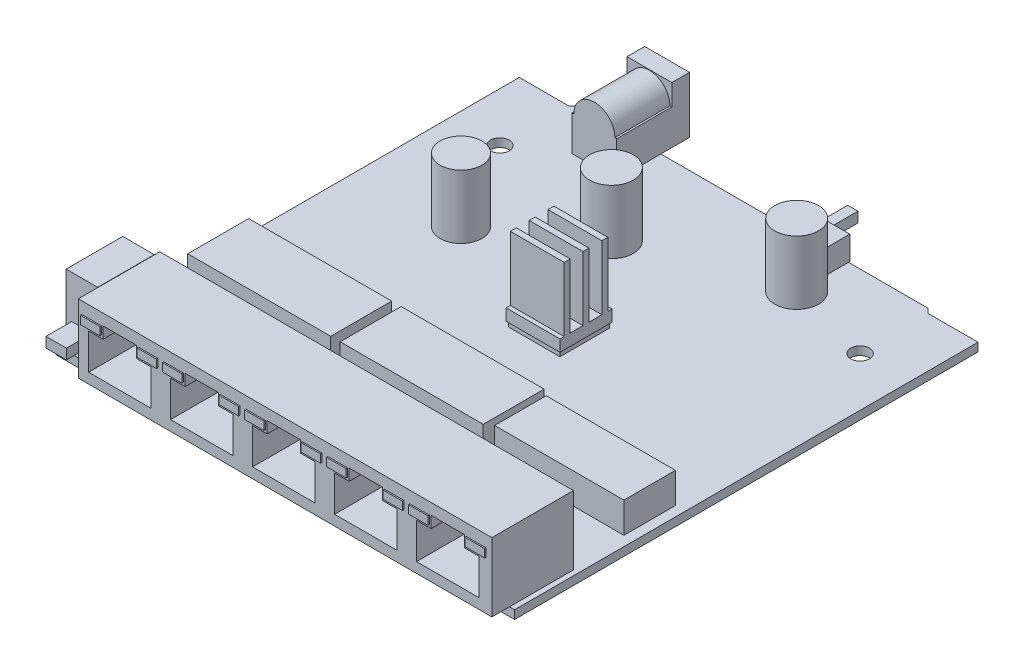
from build123d import *

# Parameters (mm, degrees)
BOSS_EXTRUDE1_DEPTH  = 1.65
SKETCH3_W            = 80.7
SKETCH3_H            = 15.9
BOSS_EXTRUDE2_DEPTH  = 13.41
SKETCH4_R            = 1.825
CUT_EXTRUDE1_DEPTH   = 2.65
SKETCH5_W            = 6.15
SKETCH5_H            = 11.05
BOSS_EXTRUDE3_DEPTH  = 12.32
SKETCH6_W            = 4
SKETCH6_H            = 2
BOSS_EXTRUDE4_DEPTH  = 5
CUT_EXTRUDE2_DEPTH   = 11.55
SKETCH8_W            = 27.9
SKETCH8_H            = 11.9
SKETCH8_W_2          = 25.22
SKETCH8_H_2          = 10.05
BOSS_EXTRUDE5_DEPTH  = 5.95
SKETCH9_W            = 10
SKETCH9_H            = 9.66
BOSS_EXTRUDE6_DEPTH  = 1
SKETCH10_W           = 10.5
SKETCH10_H           = 10.16
BOSS_EXTRUDE7_DEPTH  = 14.78
CUT_EXTRUDE3_REACH   = 50.58
SKETCH11_W           = 2.5
SKETCH11_H           = 12.52
SKETCH11_W_2         = 0.825
SKETCH12_R           = 4.275
SKETCH12_R_2         = 4.085
BOSS_EXTRUDE8_DEPTH  = 12.4
SKETCH14_W           = 8.75
SKETCH14_H           = 14.2
BOSS_EXTRUDE9_DEPTH  = 11
SKETCH15_R           = 3.1
SKETCH15_R_2         = 0.8
CUT_EXTRUDE4_DEPTH   = 9.92
CUT_EXTRUDE5_DEPTH   = 10.75
SKETCH18_W           = 8.65
SKETCH18_H           = 4.41
BOSS_EXTRUDE10_DEPTH = 4.64
SKETCH19_W           = 2
SKETCH19_H           = 2
BOSS_EXTRUDE11_DEPTH = 6
SKETCH20_W           = 3.8
SKETCH20_H           = 1.6
BOSS_EXTRUDE12_DEPTH = 0.25


with BuildPart() as part:
    # Sketch1 → Boss-Extrude1 (new body)
    with BuildSketch(Plane(origin=(0, 0, 0), x_dir=(1, 0, 0), z_dir=(0, 1, 0))):
        Polygon((44.75, 44.78), (35, 44.78), (34.13, 45.65), (-34.13, 45.65), (-35, 44.78), (-44.75, 44.78), (-44.75, -45.65), (44.75, -45.65), align=None)
    extrude(amount=BOSS_EXTRUDE1_DEPTH)

    # Sketch3 → Boss-Extrude2 (add)
    with BuildSketch(Plane(origin=(0, 1.65, 0), x_dir=(1, 0, 0), z_dir=(0, 1, 0))):
        with Locations((3.4, -41.12)):
            Rectangle(SKETCH3_W, SKETCH3_H)
    extrude(amount=BOSS_EXTRUDE2_DEPTH)

    # Sketch4 → Cut-Extrude1 (cut, through all)
    with BuildSketch(Plane(origin=(0, 1.65, 0), x_dir=(1, 0, 0), z_dir=(0, 1, 0))):
        with Locations((35.15, 31.38)):
            Circle(SKETCH4_R)
        with Locations((-35.15, 31.38)):
            Circle(SKETCH4_R)
    extrude(amount=-CUT_EXTRUDE1_DEPTH, mode=Mode.SUBTRACT)

    # Sketch5 → Boss-Extrude3 (add)
    with BuildSketch(Plane(origin=(0, 1.65, 0), x_dir=(1, 0, 0), z_dir=(0, 1, 0))):
        with Locations((-41.175, -38.625)):
            Rectangle(SKETCH5_W, SKETCH5_H)
    extrude(amount=BOSS_EXTRUDE3_DEPTH)

    # Sketch6 → Boss-Extrude4 (add)
    with BuildSketch(Plane.XY.offset(44.15)):
        with Locations((-41.175, 4.65)):
            Rectangle(SKETCH6_W, SKETCH6_H)
    extrude(amount=BOSS_EXTRUDE4_DEPTH)

    # Sketch7 → Cut-Extrude2 (cut)
    with BuildSketch(Plane.XY.offset(49.07)):
        Polygon((-34.95, 10.65), (-34.95, 3.65), (-22.75, 3.65), (-22.75, 10.65), (-25.6, 10.65), (-25.6, 12.9), (-32.1, 12.9), (-32.1, 10.65), align=None)
        Polygon((-18.95, 10.65), (-18.95, 3.65), (-6.75, 3.65), (-6.75, 10.65), (-9.6, 10.65), (-9.6, 12.9), (-16.1, 12.9), (-16.1, 10.65), align=None)
        Polygon((-2.95, 10.65), (-2.95, 3.65), (9.25, 3.65), (9.25, 10.65), (6.4, 10.65), (6.4, 12.9), (-0.1, 12.9), (-0.1, 10.65), align=None)
        Polygon((13.05, 10.65), (13.05, 3.65), (25.25, 3.65), (25.25, 10.65), (22.4, 10.65), (22.4, 12.9), (15.9, 12.9), (15.9, 10.65), align=None)
        Polygon((29.05, 10.65), (29.05, 3.65), (41.25, 3.65), (41.25, 10.65), (38.4, 10.65), (38.4, 12.9), (31.9, 12.9), (31.9, 10.65), align=None)
    extrude(amount=-CUT_EXTRUDE2_DEPTH, mode=Mode.SUBTRACT)

    # Sketch8 → Boss-Extrude5 (add)
    with BuildSketch(Plane(origin=(0, 1.65, 0), x_dir=(1, 0, 0), z_dir=(0, 1, 0))):
        with Locations((-27.4, -17.37)):
            Rectangle(SKETCH8_W, SKETCH8_H)
        with Locations((2.35, -17.37)):
            Rectangle(SKETCH8_W, SKETCH8_H)
        with Locations((30.22, -17.37)):
            Rectangle(SKETCH8_W_2, SKETCH8_H_2)
    extrude(amount=BOSS_EXTRUDE5_DEPTH)

    # Sketch9 → Boss-Extrude6 (add)
    with BuildSketch(Plane(origin=(0, 1.65, 0), x_dir=(1, 0, 0), z_dir=(0, 1, 0))):
        with Locations((1.42, 6.37)):
            Rectangle(SKETCH9_W, SKETCH9_H)
    extrude(amount=BOSS_EXTRUDE6_DEPTH)

    # Sketch10 → Boss-Extrude7 (add)
    with BuildSketch(Plane(origin=(0, 2.65, 0), x_dir=(1, 0, 0), z_dir=(0, 1, 0))):
        with Locations((1.42, 6.37)):
            Rectangle(SKETCH10_W, SKETCH10_H)
    extrude(amount=BOSS_EXTRUDE7_DEPTH)

    # Sketch11 → Cut-Extrude3 (cut, up to next)
    with BuildSketch(Plane.ZY.offset(3.83), mode=Mode.PRIVATE) as cut_extrude3_sk1:
        with Locations((-8.205, 11.17)):
            Rectangle(SKETCH11_W, SKETCH11_H)
    cut_extrude3_tool1 = extrude(cut_extrude3_sk1.sketch, amount=-CUT_EXTRUDE3_REACH, mode=Mode.PRIVATE) & part.part
    add(cut_extrude3_tool1.solids().sort_by_distance((-3.83, 11.17, -8.205))[0], mode=Mode.SUBTRACT)
    # Sketch11 → Cut-Extrude3 (cut, up to next)
    with BuildSketch(Plane.ZY.offset(3.83), mode=Mode.PRIVATE) as cut_extrude3_sk2:
        with Locations((-4.535, 11.17)):
            Rectangle(SKETCH11_W, SKETCH11_H)
    cut_extrude3_tool2 = extrude(cut_extrude3_sk2.sketch, amount=-CUT_EXTRUDE3_REACH, mode=Mode.PRIVATE) & part.part
    add(cut_extrude3_tool2.solids().sort_by_distance((-3.83, 11.17, -4.535))[0], mode=Mode.SUBTRACT)
    # Sketch11 → Cut-Extrude3 (cut, up to next)
    with BuildSketch(Plane.ZY.offset(3.83), mode=Mode.PRIVATE) as cut_extrude3_sk3:
        with Locations((-11.0375, 11.17)):
            Rectangle(SKETCH11_W_2, SKETCH11_H)
    cut_extrude3_tool3 = extrude(cut_extrude3_sk3.sketch, amount=-CUT_EXTRUDE3_REACH, mode=Mode.PRIVATE) & part.part
    add(cut_extrude3_tool3.solids().sort_by_distance((-3.83, 11.17, -11.0375))[0], mode=Mode.SUBTRACT)
    # Sketch11 → Cut-Extrude3 (cut, up to next)
    with BuildSketch(Plane.ZY.offset(3.83), mode=Mode.PRIVATE) as cut_extrude3_sk4:
        with Locations((-1.7025, 11.17)):
            Rectangle(SKETCH11_W_2, SKETCH11_H)
    cut_extrude3_tool4 = extrude(cut_extrude3_sk4.sketch, amount=-CUT_EXTRUDE3_REACH, mode=Mode.PRIVATE) & part.part
    add(cut_extrude3_tool4.solids().sort_by_distance((-3.83, 11.17, -1.7025))[0], mode=Mode.SUBTRACT)

    # Sketch12 → Boss-Extrude8 (add)
    with BuildSketch(Plane(origin=(0, 1.65, 0), x_dir=(1, 0, 0), z_dir=(0, 1, 0))):
        with Locations((18.5, 35.65)):
            Circle(SKETCH12_R)
        with Locations((-8.15, 26.15)):
            Circle(SKETCH12_R)
        with Locations((-25.25, 13.9)):
            Circle(SKETCH12_R_2)
    extrude(amount=BOSS_EXTRUDE8_DEPTH)

    # Sketch14 → Boss-Extrude9 (add)
    with BuildSketch(Plane(origin=(0, 1.65, 0), x_dir=(1, 0, 0), z_dir=(0, 1, 0))):
        with Locations((-22.375, 44.14)):
            Rectangle(SKETCH14_W, SKETCH14_H)
    extrude(amount=BOSS_EXTRUDE9_DEPTH)

    # Sketch15 → Cut-Extrude4 (cut)
    with BuildSketch(Plane(origin=(0, 0, -51.24), x_dir=(-1, 0, 0), z_dir=(0, 0, -1))):
        with Locations((22.375, 8.533333602)):
            Circle(SKETCH15_R)
        with Locations((22.375, 8.533333602)):
            Circle(SKETCH15_R_2, mode=Mode.SUBTRACT)
    extrude(amount=-CUT_EXTRUDE4_DEPTH, mode=Mode.SUBTRACT)

    # Sketch17 → Cut-Extrude5 (cut)
    with BuildSketch(Plane.XY.offset(-37.04)):
        with BuildLine():
            Line((-26.375, 8.533333602), (-26.75, 8.533333602))
            Line((-26.75, 8.533333602), (-26.75, 12.65))
            Line((-26.75, 12.65), (-18, 12.65))
            Line((-18, 12.65), (-18, 8.533333602))
            Line((-18, 8.533333602), (-18.375, 8.533333602))
            ThreePointArc((-18.375, 8.533333602), (-22.375, 12.533333602), (-26.375, 8.533333602))
        make_face()
    extrude(amount=-CUT_EXTRUDE5_DEPTH, mode=Mode.SUBTRACT)

    # Sketch18 → Boss-Extrude10 (add)
    with BuildSketch(Plane(origin=(0, 1.65, 0), x_dir=(1, 0, 0), z_dir=(0, 1, 0))):
        with Locations((14.295, 43.695)):
            Rectangle(SKETCH18_W, SKETCH18_H)
    extrude(amount=BOSS_EXTRUDE10_DEPTH)

    # Sketch19 → Boss-Extrude11 (add)
    with BuildSketch(Plane(origin=(0, 0, -45.9), x_dir=(-1, 0, 0), z_dir=(0, 0, -1))):
        with Locations((-13.22, 3.97)):
            Rectangle(SKETCH19_W, SKETCH19_H)
    extrude(amount=BOSS_EXTRUDE11_DEPTH)

    # Sketch20 → Boss-Extrude12 (add)
    with BuildSketch(Plane.XY.offset(49.07)):
        with Locations((-34.365, 11.95)):
            Rectangle(SKETCH20_W, SKETCH20_H)
        with Locations((-23.335, 11.95)):
            Rectangle(SKETCH20_W, SKETCH20_H)
        with Locations((-7.335, 11.95)):
            Rectangle(SKETCH20_W, SKETCH20_H)
        with Locations((-18.365, 11.95)):
            Rectangle(SKETCH20_W, SKETCH20_H)
        with Locations((8.665, 11.95)):
            Rectangle(SKETCH20_W, SKETCH20_H)
        with Locations((-2.365, 11.95)):
            Rectangle(SKETCH20_W, SKETCH20_H)
        with Locations((24.665, 11.95)):
            Rectangle(SKETCH20_W, SKETCH20_H)
        with Locations((13.635, 11.95)):
            Rectangle(SKETCH20_W, SKETCH20_H)
        with Locations((40.665, 11.95)):
            Rectangle(SKETCH20_W, SKETCH20_H)
        with Locations((29.635, 11.95)):
            Rectangle(SKETCH20_W, SKETCH20_H)
    extrude(amount=BOSS_EXTRUDE12_DEPTH)


solid = part.part
